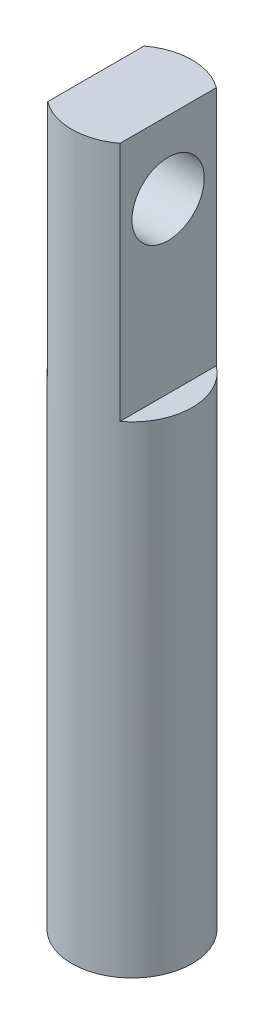
from build123d import *

# Parameters (mm, degrees)
SKETCH1_R          = 2.54
EXTRUDE1_DEPTH     = 30.48
SKETCH2_W          = 2.032
SKETCH2_H          = 9.951877561
SKETCH2_W_2        = 1.949333431
SKETCH2_H_2        = 9.106721584
CUT_EXTRUDE1_DEPTH = 10.16
SKETCH4_R          = 1.524
CUT_EXTRUDE2_DEPTH = 10


with BuildPart() as part:
    # Sketch1 → Extrude1 (new body)
    with BuildSketch(Plane(origin=(0, 0, 0), x_dir=(1, 0, 0), z_dir=(0, 1, 0))):
        Circle(SKETCH1_R)
    extrude(amount=EXTRUDE1_DEPTH)

    # Sketch2 → Cut-Extrude1 (cut)
    with BuildSketch(Plane(origin=(0, 30.48, 0), x_dir=(-1, 0, 0), z_dir=(0, 1, 0))):
        with Locations((-2.54, 0.177802653)):
            Rectangle(SKETCH2_W, SKETCH2_H)
        with Locations((2.498666716, 0.600380641)):
            Rectangle(SKETCH2_W_2, SKETCH2_H_2)
    extrude(amount=-CUT_EXTRUDE1_DEPTH, mode=Mode.SUBTRACT)

    # Sketch4 → Cut-Extrude2 (cut)
    with BuildSketch(Plane.ZY.offset(1.524)):
        with Locations((0, 27.432)):
            Circle(SKETCH4_R)
    extrude(amount=-CUT_EXTRUDE2_DEPTH, mode=Mode.SUBTRACT)


solid = part.part
